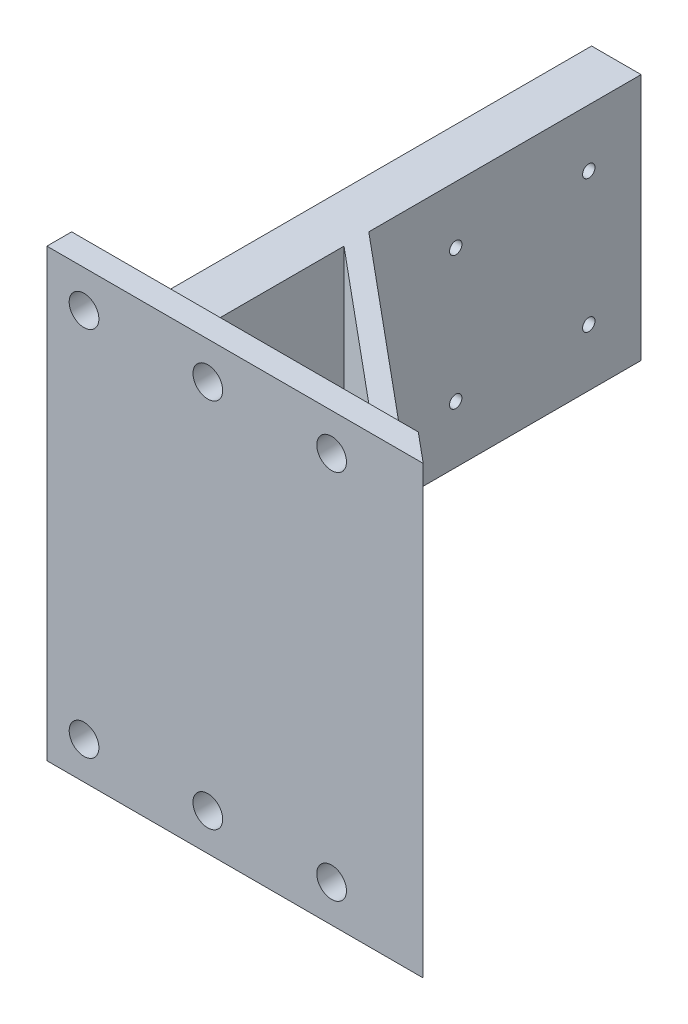
from build123d import *

# Parameters (mm, degrees)
EXTRUDE_1_DEPTH     = 50
SKETCH_2_W          = 76
SKETCH_2_H          = 20
EXTRUDE_2_DEPTH     = 5
CUT_EXTRUDE_1_DEPTH = 44
SKETCH_5_R          = 1.25
CUT_EXTRUDE_2_DEPTH = 77
SKETCH_6_R          = 3
CUT_EXTRUDE_3_DEPTH = 6


with BuildPart() as part:
    # 草图1 → 凸台-拉伸1 (new body)
    with BuildSketch(Plane(origin=(0, 0, 0), x_dir=(1, 0, 0), z_dir=(0, 1, 0))):
        Polygon((0, 0), (0, 110), (10, 110), (10, 55), (76, 0), (70, 0), (10, 0), align=None)
        Polygon((64, 5), (10, 50), (10, 5), align=None, mode=Mode.SUBTRACT)
    extrude(amount=EXTRUDE_1_DEPTH)

    # 草图2 → 凸台-拉伸2 (add)
    with BuildSketch(Plane.XY):
        with Locations((38, 60)):
            Rectangle(SKETCH_2_W, SKETCH_2_H)
    extrude_2 = extrude(amount=-EXTRUDE_2_DEPTH)

    # 草图3 → 切除-拉伸1 (cut)
    with BuildSketch(Plane.XZ.offset(-50)):
        Polygon((70, -5), (76, 0), (76, -5), align=None)
    cut_extrude_1 = extrude(amount=-CUT_EXTRUDE_1_DEPTH, mode=Mode.SUBTRACT)

    # 镜向1: 凸台-拉伸2, 切除-拉伸1 across plane
    add(extrude_2.mirror(Plane(origin=(0, 25, 0), x_dir=(0, 0, 1), z_dir=(0, -1, 0))))
    add(cut_extrude_1.mirror(Plane(origin=(0, 25, 0), x_dir=(0, 0, 1), z_dir=(0, -1, 0))), mode=Mode.SUBTRACT)

    # 草图5 → 切除-拉伸2 (cut, through all)
    with BuildSketch(Plane.ZY):
        with Locations((-72.564971157, 38.435028843)):
            Circle(SKETCH_5_R)
        with Locations((-72.564971157, 11.564971157)):
            Circle(SKETCH_5_R)
        with Locations((-99.435028843, 11.564971157)):
            Circle(SKETCH_5_R)
        with Locations((-99.435028843, 38.435028843)):
            Circle(SKETCH_5_R)
    extrude(amount=-CUT_EXTRUDE_2_DEPTH, mode=Mode.SUBTRACT)

    # 草图6 → 切除-拉伸3 (cut, through all)
    with BuildSketch(Plane(origin=(0, 0, -5), x_dir=(-1, 0, 0), z_dir=(0, 0, -1))):
        with Locations((-7.5, 62.5)):
            Circle(SKETCH_6_R)
        with Locations((-32.5, 62.5)):
            Circle(SKETCH_6_R)
        with Locations((-57.5, 62.5)):
            Circle(SKETCH_6_R)
    cut_extrude_3 = extrude(amount=-CUT_EXTRUDE_3_DEPTH, mode=Mode.SUBTRACT)

    # 镜向2: 切除-拉伸3 across plane
    add(cut_extrude_3.mirror(Plane(origin=(0, 25, 0), x_dir=(0, 0, 1), z_dir=(0, -1, 0))), mode=Mode.SUBTRACT)


solid = part.part
